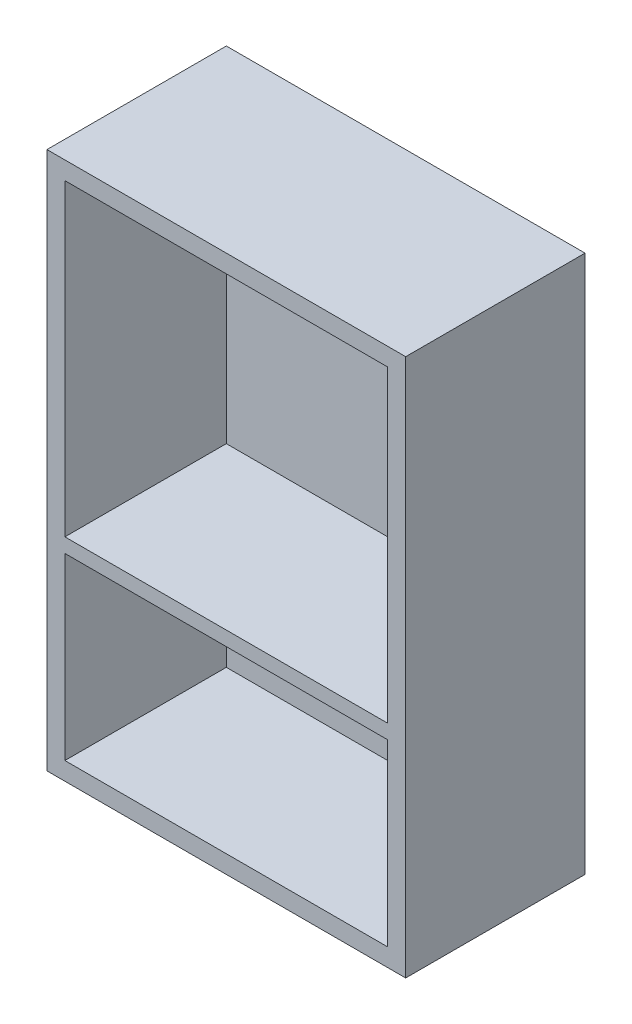
from build123d import *

# Parameters (mm, degrees)
SKETCH1_W           = 100
SKETCH1_H           = 150
BOSS_EXTRUDE1_DEPTH = 5
SKETCH2_W           = 100
SKETCH2_H           = 150
SKETCH2_W_2         = 90
SKETCH2_H_2         = 86
SKETCH2_H_3         = 50
BOSS_EXTRUDE2_DEPTH = 45


with BuildPart() as part:
    # Sketch1 → Boss-Extrude1 (new body)
    with BuildSketch(Plane.XY):
        Rectangle(SKETCH1_W, SKETCH1_H)
    extrude(amount=BOSS_EXTRUDE1_DEPTH)

    # Sketch2 → Boss-Extrude2 (add)
    with BuildSketch(Plane.XY.offset(5)):
        Rectangle(SKETCH2_W, SKETCH2_H)
        with Locations((0, 27)):
            Rectangle(SKETCH2_W_2, SKETCH2_H_2, mode=Mode.SUBTRACT)
        with Locations((0, -45)):
            Rectangle(SKETCH2_W_2, SKETCH2_H_3, mode=Mode.SUBTRACT)
    extrude(amount=BOSS_EXTRUDE2_DEPTH)


solid = part.part
